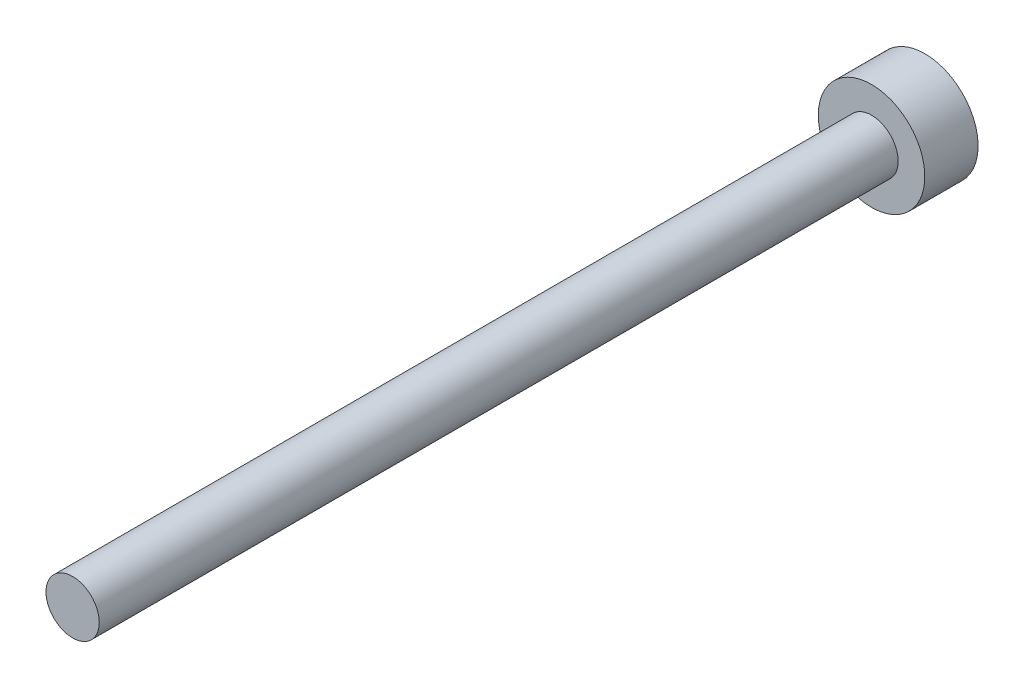
from build123d import *

# Parameters (mm, degrees)
SKETCH_1_R      = 1.5
EXTRUDE_1_DEPTH = 45
SKETCH_2_R      = 3
EXTRUDE_2_DEPTH = 3


with BuildPart() as part:
    # 草图1 → 凸台-拉伸1 (new body)
    with BuildSketch(Plane.XY):
        Circle(SKETCH_1_R)
    extrude(amount=EXTRUDE_1_DEPTH)

    # 草图2 → 凸台-拉伸2 (add)
    with BuildSketch(Plane(origin=(0, 0, 0), x_dir=(-1, 0, 0), z_dir=(0, 0, -1))):
        Circle(SKETCH_2_R)
    extrude(amount=EXTRUDE_2_DEPTH)


solid = part.part
